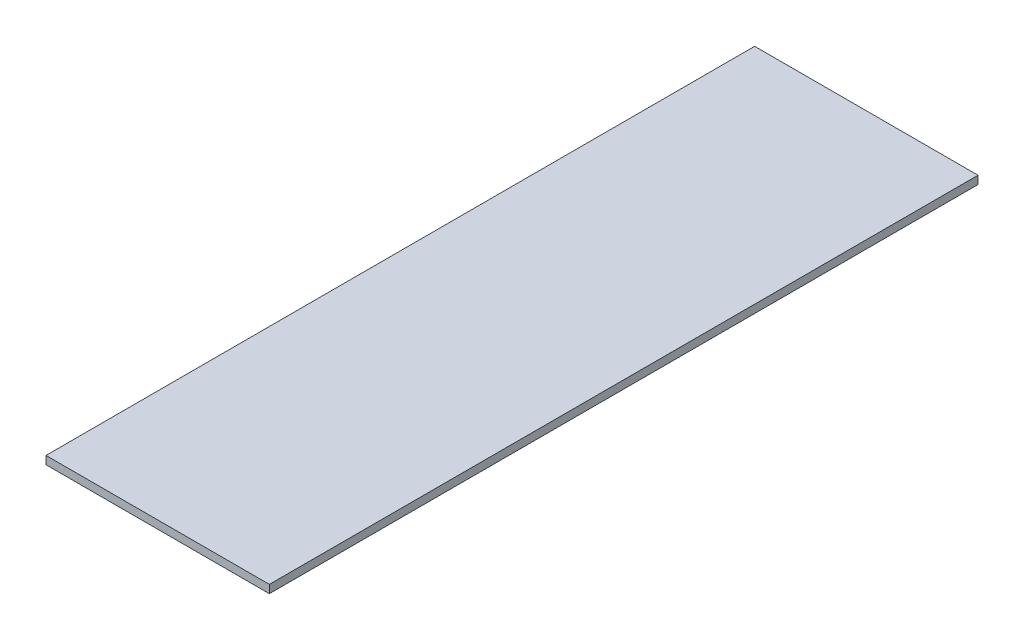
from build123d import *

# Parameters (mm, degrees)
SKETCH_1_W      = 498
SKETCH_1_H      = 1580
EXTRUDE_1_DEPTH = 18


with BuildPart() as part:
    # Эскиз1 → Бобышка-Вытянуть1 (new body)
    with BuildSketch(Plane(origin=(0, 0, 0), x_dir=(1, 0, 0), z_dir=(0, 1, 0))):
        Rectangle(SKETCH_1_W, SKETCH_1_H)
    extrude(amount=EXTRUDE_1_DEPTH)


solid = part.part
